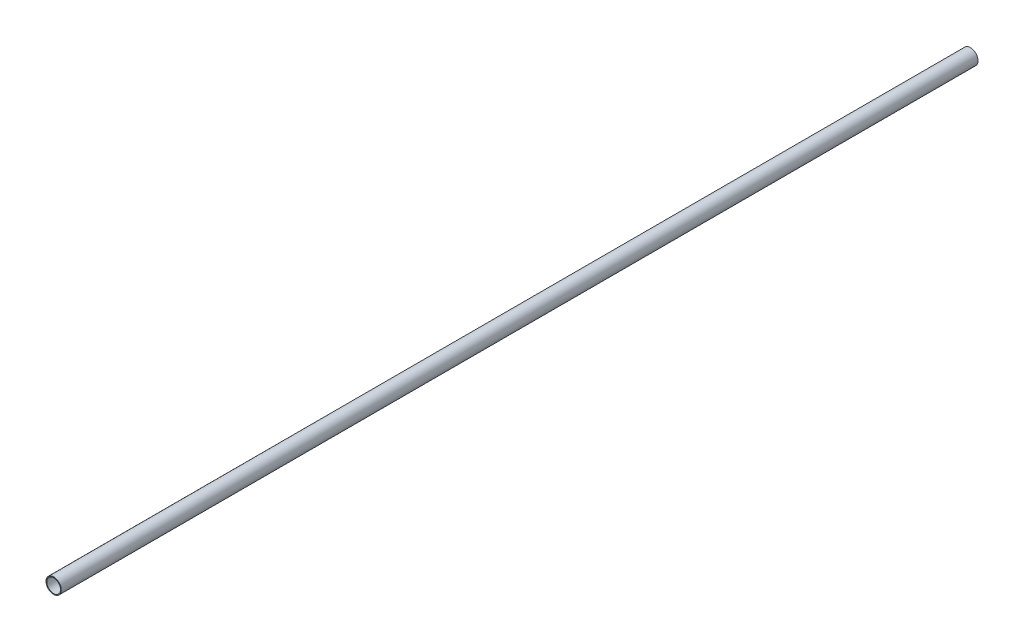
from build123d import *

# Parameters (mm, degrees)
SKETCH_1_R      = 10
SKETCH_1_R_2    = 9
EXTRUDE_1_DEPTH = 600


with BuildPart() as part:
    # Эскиз1 → Бобышка-Вытянуть1 (new body, symmetric)
    with BuildSketch(Plane.XY):
        Circle(SKETCH_1_R)
        Circle(SKETCH_1_R_2, mode=Mode.SUBTRACT)
    extrude(amount=EXTRUDE_1_DEPTH, both=True)


solid = part.part
